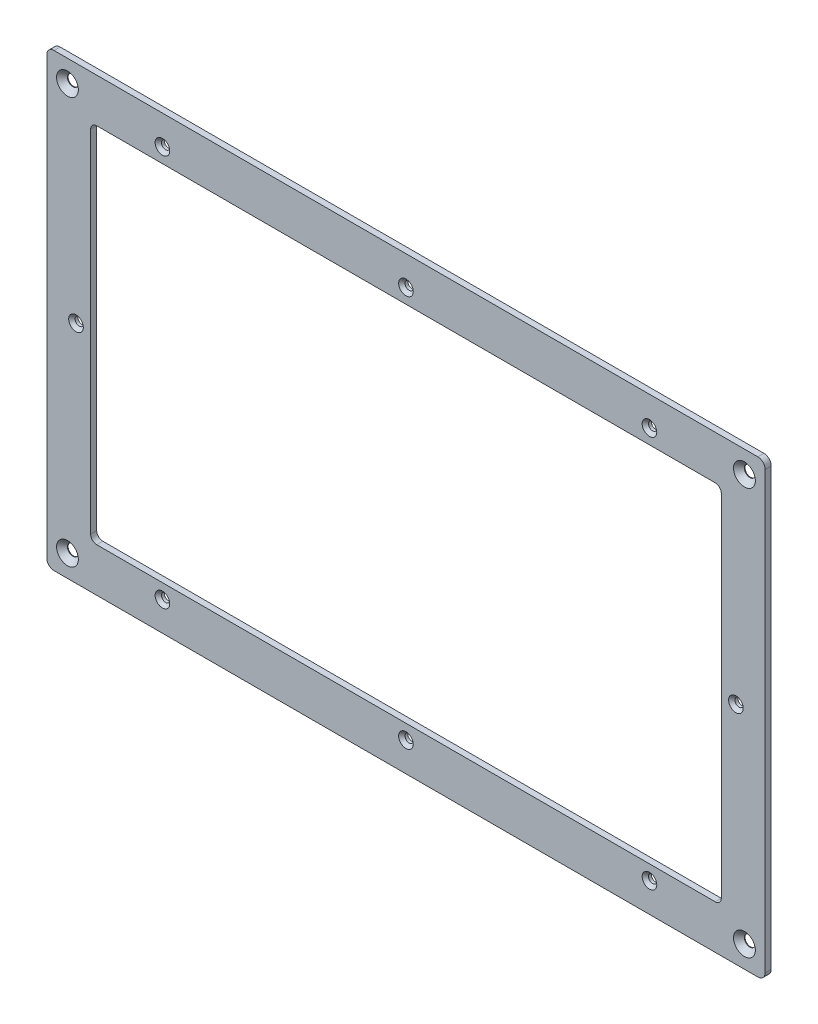
from build123d import *

# Parameters (mm, degrees)
EXTRUDE1_DEPTH                   = 1.25
CUT_EXTRUDE4_DEPTH               = 3.5
FURO_COM_FOLGA_DE_M31_AT_2_COUNT = 2
FURO_COM_FOLGA_DE_M31_AT_2_PITCH = 100
FURO_COM_FOLGA_DE_M31_AT_3_COUNT = 2
FURO_COM_FOLGA_DE_M31_AT_3_PITCH = 100
FURO_COM_FOLGA_DE_M31_AT_4_COUNT = 2
FURO_COM_FOLGA_DE_M31_AT_4_PITCH = 157.608692654
FURO_COM_FOLGA_DE_M31_AT_5_COUNT = 2
FURO_COM_FOLGA_DE_M31_AT_5_PITCH = 157.608692654


with BuildPart() as part:
    # Sketch1 → Extrude1 (new body, symmetric)
    with BuildSketch(Plane.XY):
        with BuildLine():
            Line((-144.5, 92.5), (144.5, 92.5))
            ThreePointArc((144.5, 92.5), (146.621320344, 91.621320344), (147.5, 89.5))
            Line((147.5, 89.5), (147.5, -89.5))
            ThreePointArc((147.5, -89.5), (146.621320344, -91.621320344), (144.5, -92.5))
            Line((144.5, -92.5), (-144.5, -92.5))
            ThreePointArc((-144.5, -92.5), (-146.621320344, -91.621320344), (-147.5, -89.5))
            Line((-147.5, -89.5), (-147.5, 89.5))
            ThreePointArc((-147.5, 89.5), (-146.621320344, 91.621320344), (-144.5, 92.5))
        make_face()
    extrude(amount=EXTRUDE1_DEPTH, both=True)

    # Sketch5 → Cut-Extrude4 (cut, through all)
    with BuildSketch(Plane.XY.offset(1.25)):
        with BuildLine():
            Line((-127, 74.5), (127, 74.5))
            ThreePointArc((127, 74.5), (128.767766953, 73.767766953), (129.5, 72))
            Line((129.5, 72), (129.5, -72))
            ThreePointArc((129.5, -72), (128.767766953, -73.767766953), (127, -74.5))
            Line((127, -74.5), (-127, -74.5))
            ThreePointArc((-127, -74.5), (-128.767766953, -73.767766953), (-129.5, -72))
            Line((-129.5, -72), (-129.5, 72))
            ThreePointArc((-129.5, 72), (-128.767766953, 73.767766953), (-127, 74.5))
        make_face()
    extrude(amount=-CUT_EXTRUDE4_DEPTH, mode=Mode.SUBTRACT)

    # Esboço1 → Escareado para SFHCS M41 (revolve, cut)
    with BuildSketch(Plane(origin=(139, 83.5, 1.25), x_dir=(0, -1, 0), z_dir=(1, 0, 0))):
        Polygon((0, 0), (0, 2.5), (2.25, 2.5), (2.25, 2.23), (4.48, 0), align=None)
    escareado_para_sfhcs_m41 = revolve(axis=Axis((139, 83.5, 7.6), (0, 0, -1)), mode=Mode.SUBTRACT)

    # Esboço3 → Furo com folga de M31 (revolve, cut)
    with BuildSketch(Plane(origin=(0, -80.5, 1.25), x_dir=(0, -1, 0), z_dir=(1, 0, 0))):
        Polygon((0, 0), (0, 2.5), (1.7, 2.5), (1.7, 1.3), (3, 0), align=None)
    furo_com_folga_de_m31 = revolve(axis=Axis((0, -80.5, 7.6), (0, 0, -1)), mode=Mode.SUBTRACT)

    # Furo com folga de M31 at 2: Furo com folga de M31 ×2
    with Locations(*[(-i * FURO_COM_FOLGA_DE_M31_AT_2_PITCH, 0, 0) for i in range(1, FURO_COM_FOLGA_DE_M31_AT_2_COUNT)]):
        add(furo_com_folga_de_m31, mode=Mode.SUBTRACT)

    # Furo com folga de M31 at 3: Furo com folga de M31 ×2
    with Locations(*[(i * FURO_COM_FOLGA_DE_M31_AT_3_PITCH, 0, 0) for i in range(1, FURO_COM_FOLGA_DE_M31_AT_3_COUNT)]):
        add(furo_com_folga_de_m31, mode=Mode.SUBTRACT)

    # Furo com folga de M31 at 4: Furo com folga de M31 ×2
    with Locations(*[Vector(-0.859724154, 0.51075863, 0) * (i * FURO_COM_FOLGA_DE_M31_AT_4_PITCH) for i in range(1, FURO_COM_FOLGA_DE_M31_AT_4_COUNT)]):
        add(furo_com_folga_de_m31, mode=Mode.SUBTRACT)

    # Furo com folga de M31 at 5: Furo com folga de M31 ×2
    with Locations(*[Vector(0.859724154, 0.51075863, 0) * (i * FURO_COM_FOLGA_DE_M31_AT_5_PITCH) for i in range(1, FURO_COM_FOLGA_DE_M31_AT_5_COUNT)]):
        add(furo_com_folga_de_m31, mode=Mode.SUBTRACT)

    # Espelhar1: Furo com folga de M31 across plane
    add(furo_com_folga_de_m31.mirror(Plane.ZX), mode=Mode.SUBTRACT)

    # Espelhar1 copy 1 sketch → Espelhar1 copy 1 (revolve, cut)
    with BuildSketch(Plane(origin=(-100, 80.5, 1.25), x_dir=(0, 1, 0), z_dir=(1, 0, 0))):
        Polygon((0, 0), (0, -2.5), (1.7, -2.5), (1.7, -1.3), (3, 0), align=None)
    revolve(axis=Axis((-100, 80.5, 7.6), (0, 0, 1)), mode=Mode.SUBTRACT)

    # Espelhar1 copy 2 sketch → Espelhar1 copy 2 (revolve, cut)
    with BuildSketch(Plane(origin=(100, 80.5, 1.25), x_dir=(0, 1, 0), z_dir=(1, 0, 0))):
        Polygon((0, 0), (0, -2.5), (1.7, -2.5), (1.7, -1.3), (3, 0), align=None)
    revolve(axis=Axis((100, 80.5, 7.6), (0, 0, 1)), mode=Mode.SUBTRACT)

    # Espelhar1 copy 3 sketch → Espelhar1 copy 3 (revolve, cut)
    with BuildSketch(Plane(origin=(-135.5, 0, 1.25), x_dir=(0, 1, 0), z_dir=(1, 0, 0))):
        Polygon((0, 0), (0, -2.5), (1.7, -2.5), (1.7, -1.3), (3, 0), align=None)
    revolve(axis=Axis((-135.5, 0, 7.6), (0, 0, 1)), mode=Mode.SUBTRACT)

    # Espelhar1 copy 4 sketch → Espelhar1 copy 4 (revolve, cut)
    with BuildSketch(Plane(origin=(135.5, 0, 1.25), x_dir=(0, 1, 0), z_dir=(1, 0, 0))):
        Polygon((0, 0), (0, -2.5), (1.7, -2.5), (1.7, -1.3), (3, 0), align=None)
    revolve(axis=Axis((135.5, 0, 7.6), (0, 0, 1)), mode=Mode.SUBTRACT)

    # Espelhar2: Escareado para SFHCS M41 across plane
    add(escareado_para_sfhcs_m41.mirror(Plane(origin=(0, 0, 0), x_dir=(0, 0, 1), z_dir=(1, 0, 0))), mode=Mode.SUBTRACT)

    # Espelhar3: Escareado para SFHCS M41 across plane
    add(escareado_para_sfhcs_m41.mirror(Plane.ZX), mode=Mode.SUBTRACT)

    # Espelhar3 copy 1 sketch → Espelhar3 copy 1 (revolve, cut)
    with BuildSketch(Plane(origin=(-139, -83.5, 1.25), x_dir=(0, 1, 0), z_dir=(-1, 0, 0))):
        Polygon((0, 0), (0, 2.5), (2.25, 2.5), (2.25, 2.23), (4.48, 0), align=None)
    revolve(axis=Axis((-139, -83.5, 7.6), (0, 0, -1)), mode=Mode.SUBTRACT)


solid = part.part
